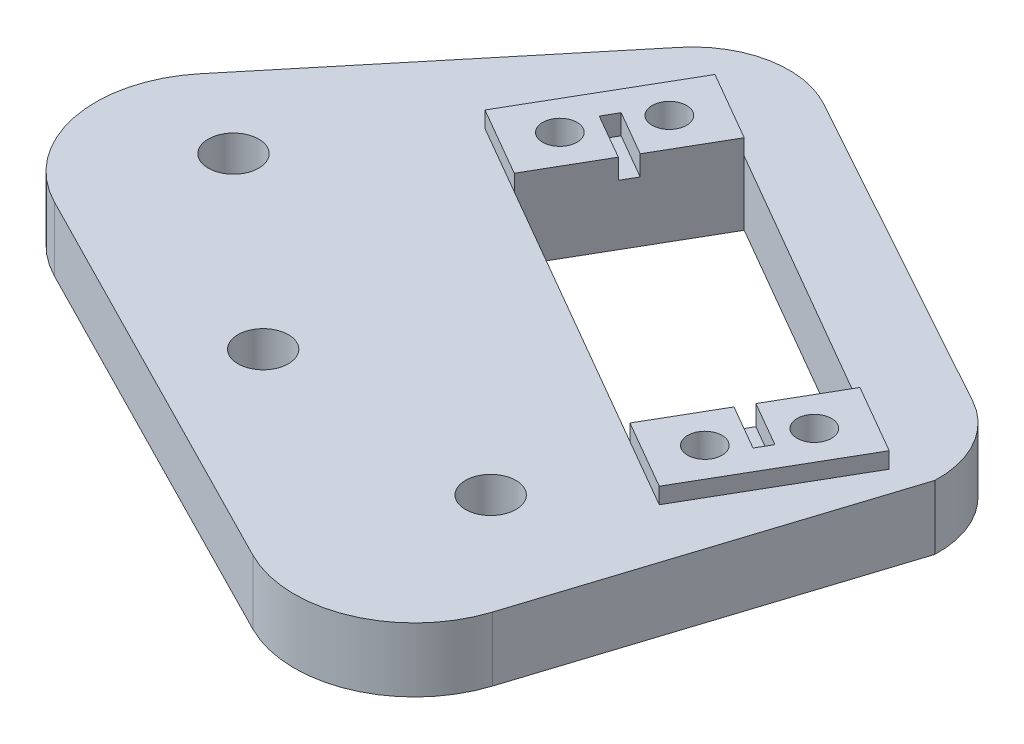
from build123d import *

# Parameters (mm, degrees)
BOSS_EXTRUDE2_DEPTH = 8
SKETCH2_R           = 3.15
CUT_EXTRUDE1_DEPTH  = 8
BOSS_EXTRUDE4_DEPTH = 2
CUT_EXTRUDE2_DEPTH  = 14
SKETCH5_R           = 2.15
CUT_EXTRUDE3_DEPTH  = 14
SKETCH6_R           = 3.5
CUT_EXTRUDE4_DEPTH  = 2.6
CUT_EXTRUDE5_DEPTH  = 18.5
BOSS_EXTRUDE7_DEPTH = 8
SKETCH9_R           = 3.15
CUT_EXTRUDE6_DEPTH  = 8
CUT_EXTRUDE8_DEPTH  = 8
BOSS_EXTRUDE8_DEPTH = 8
CUT_EXTRUDE9_DEPTH  = 2.5


with BuildPart() as part:
    # Sketch1 → Boss-Extrude2 (new body)
    with BuildSketch(Plane(origin=(0, 0, 0), x_dir=(1, 0, 0), z_dir=(0, 1, 0))):
        Polygon((-36.064195387, 30.19821093), (-36.064195387, 45.055140387), (-24.456215945, 60.508200645), (25.928290152, 75.028423128), (63.192701615, 49.978777876), (57.8600206, 4.654046233), (5.024212079, -12.575443702), (-26.79369062, -0.934399252), align=None)
    extrude(amount=BOSS_EXTRUDE2_DEPTH)

    # Sketch2 → Cut-Extrude1 (cut)
    with BuildSketch(Plane(origin=(0, 8, 0), x_dir=(1, 0, 0), z_dir=(0, 1, 0))):
        with Locations((-0.992606529, 5.023658057)):
            Circle(SKETCH2_R)
        with Locations((-23.973939823, 24.307286348)):
            Circle(SKETCH2_R)
    extrude(amount=-CUT_EXTRUDE1_DEPTH, mode=Mode.SUBTRACT)

    # Sketch3 → Boss-Extrude4 (add)
    with BuildSketch(Plane(origin=(0, 8, 0), x_dir=(1, 0, 0), z_dir=(0, 1, 0))):
        Polygon((-5.747908307, 51.79510143), (2.909877598, 46.790828933), (8.164363719, 55.881504134), (-0.493422186, 60.885776631), align=None)
        Polygon((-2.344608524, 37.700153733), (2.909877598, 46.790828933), (-5.747908307, 51.79510143), (-11.002394429, 42.70442623), align=None)
        Polygon((37.108131922, 27.023952571), (45.765917827, 22.019680074), (51.020403949, 31.110355274), (42.362618044, 36.114627771), align=None)
        Polygon((40.511431705, 12.929004873), (45.765917827, 22.019680074), (37.108131922, 27.023952571), (31.8536458, 17.93327737), align=None)
    extrude(amount=BOSS_EXTRUDE4_DEPTH)

    # Sketch4 → Cut-Extrude2 (cut)
    with BuildSketch(Plane(origin=(0, 8, 0), x_dir=(1, 0, 0), z_dir=(0, 1, 0))):
        Polygon((8.164363719, 55.881504134), (-2.344608524, 37.700153733), (31.8536458, 17.93327737), (42.362618044, 36.114627771), align=None)
    extrude(amount=-CUT_EXTRUDE2_DEPTH, mode=Mode.SUBTRACT)

    # Sketch5 → Cut-Extrude3 (cut)
    with BuildSketch(Plane(origin=(0, 10, 0), x_dir=(1, 0, 0), z_dir=(0, 1, 0))):
        with Locations((-3.921151603, 44.964072229)):
            Circle(SKETCH5_R)
        with Locations((1.083120894, 53.621858134)):
            Circle(SKETCH5_R)
        with Locations((43.939161123, 28.850709275)):
            Circle(SKETCH5_R)
        with Locations((38.934888626, 20.19292337)):
            Circle(SKETCH5_R)
    extrude(amount=-CUT_EXTRUDE3_DEPTH, mode=Mode.SUBTRACT)

    # Sketch6 → Cut-Extrude4 (cut)
    with BuildSketch(Plane.XZ):
        with Locations((43.939161123, -28.850709275)):
            Circle(SKETCH6_R)
        with Locations((38.934888626, -20.19292337)):
            Circle(SKETCH6_R)
        with Locations((1.083120894, -53.621858134)):
            Circle(SKETCH6_R)
        with Locations((-3.921151603, -44.964072229)):
            Circle(SKETCH6_R)
    extrude(amount=-CUT_EXTRUDE4_DEPTH, mode=Mode.SUBTRACT)

    # Sketch7 → Cut-Extrude5 (cut)
    with BuildSketch(Plane(origin=(0, 8, 0), x_dir=(1, 0, 0), z_dir=(0, 1, 0))):
        Polygon((-23.90080129, 101.032848336), (-57.901406204, 20.736967462), (-18.158957139, -32.533824917), (87.924213713, -9.961236853), (85.311975199, 49.315634488), align=None)
        Polygon((-40.820623888, 23.42964982), (-5.371906334, -12.019067733), (42.940552226, -17.400063196), (73.057764711, 41.083606285), (-8.197554073, 82.927487203), align=None, mode=Mode.SUBTRACT)
    extrude(amount=-CUT_EXTRUDE5_DEPTH, mode=Mode.SUBTRACT)

    # Sketch8 → Boss-Extrude7 (add)
    with BuildSketch(Plane(origin=(0, 8, 0), x_dir=(1, 0, 0), z_dir=(0, 1, 0))):
        Polygon((-8.197554073, 82.927487203), (-40.820623888, 23.42964982), (-5.371906334, -12.019067733), (42.940552226, -17.400063196), (73.057764711, 41.083606285), align=None)
        Polygon((7.41963674, 62.005546744), (-9.746922841, 64.747246038), (-32.401642497, 23.42964982), (0, -4.674812176), (46.197479834, 11.841771544), (56.025503799, 35.943618774), align=None, mode=Mode.SUBTRACT)
    extrude(amount=-BOSS_EXTRUDE7_DEPTH)

    # Sketch9 → Cut-Extrude6 (cut)
    with BuildSketch(Plane(origin=(0, 0, 0), x_dir=(-1, 0, 0), z_dir=(0, -1, 0))):
        with Locations((-28.941808693, 3.473889793)):
            Circle(SKETCH9_R)
    extrude(amount=-CUT_EXTRUDE6_DEPTH, mode=Mode.SUBTRACT)

    # Sketch10 → Cut-Extrude8 (cut)
    with BuildSketch(Plane(origin=(0, 8, 0), x_dir=(1, 0, 0), z_dir=(0, 1, 0))):
        Polygon((-51.027907223, 26.499697203), (-18.337970987, 89.979258173), (70.618900133, 64.73001084), (85.862243499, 8.329361683), (41.198193823, -31.646717715), (-23.676019088, -9.814381331), align=None)
        with BuildLine():
            Line((-33.872566493, 31.841833363), (-7.610913822, 63.637460521))
            ThreePointArc((-7.610913822, 63.637460521), (-0.606725689, 67.783190008), (7.431616747, 66.506171896))
            Line((7.431616747, 66.506171896), (48.870452229, 43.677060264))
            ThreePointArc((48.870452229, 43.677060264), (53.514897305, 39.092266426), (55.073012074, 32.754799821))
            Line((55.073012074, 32.754799821), (41.706263242, -9.064889609))
            ThreePointArc((41.706263242, -9.064889609), (33.18888877, -18.343686498), (20.602861854, -17.860296318))
            Line((20.602861854, -17.860296318), (-29.950777497, 7.924950794))
            ThreePointArc((-29.950777497, 7.924950794), (-37.823070784, 18.242703419), (-34.700474084, 30.839465332))
            Line((-34.700474084, 30.839465332), (-33.872566493, 31.841833363))
        make_face(mode=Mode.SUBTRACT)
    extrude(amount=-CUT_EXTRUDE8_DEPTH, mode=Mode.SUBTRACT)

    # Sketch12 → Boss-Extrude8 (add)
    with BuildSketch(Plane(origin=(0, 8, 0), x_dir=(1, 0, 0), z_dir=(0, 1, 0))):
        with BuildLine():
            Line((-34.700474084, 30.839465332), (-23.799416497, 10.878604368))
            Line((-23.799416497, 10.878604368), (16.273254251, -10.775107124))
            Line((16.273254251, -10.775107124), (41.706263242, -9.064889609))
            ThreePointArc((41.706263242, -9.064889609), (33.18888877, -18.343686498), (20.602861854, -17.860296318))
            Line((20.602861854, -17.860296318), (-29.950777497, 7.924950794))
            ThreePointArc((-29.950777497, 7.924950794), (-37.823070784, 18.242703419), (-34.700474084, 30.839465332))
        make_face()
    extrude(amount=-BOSS_EXTRUDE8_DEPTH)

    # Sketch13 → Cut-Extrude9 (cut)
    with BuildSketch(Plane(origin=(0, 10, 0), x_dir=(1, 0, 0), z_dir=(0, 1, 0))):
        Polygon((37.108131922, 27.023952571), (37.608559172, 27.889731161), (43.23612001, 24.636954038), (42.235265511, 22.905396857), (36.607704672, 26.15817398), align=None)
        Polygon((3.410304847, 47.656607524), (-2.217255991, 50.909384647), (-3.21811049, 49.177827466), (2.409450348, 45.925050343), align=None)
    extrude(amount=-CUT_EXTRUDE9_DEPTH, mode=Mode.SUBTRACT)


solid = part.part
